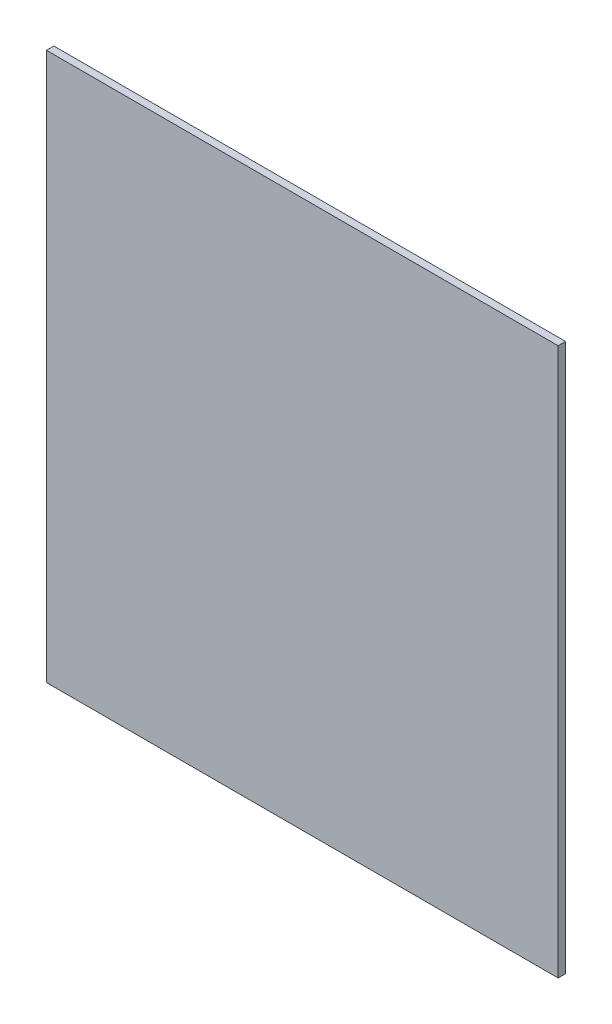
from build123d import *

# Parameters (mm, degrees)
ESBO_O1_W                = 200
ESBO_O1_H                = 214
RESSALTO_EXTRUS_O1_DEPTH = 2.9


with BuildPart() as part:
    # Esboço1 → Ressalto-extrusão1 (new body)
    with BuildSketch(Plane.XY):
        Rectangle(ESBO_O1_W, ESBO_O1_H)
    extrude(amount=RESSALTO_EXTRUS_O1_DEPTH)


solid = part.part
